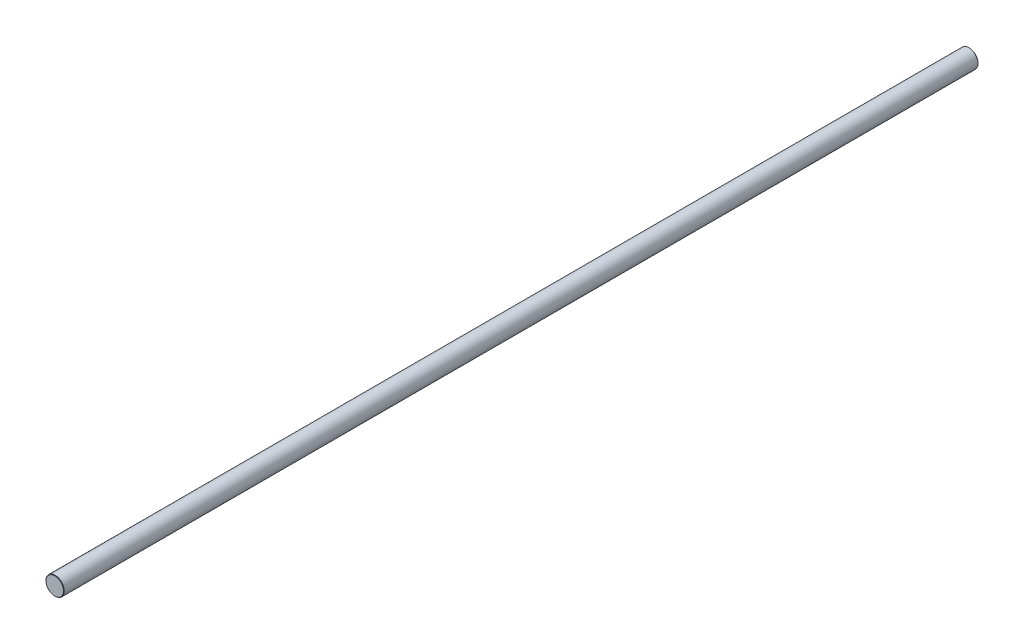
from build123d import *

# Parameters (mm, degrees)
SKETCH3_R                = 10
BOSS_EXTRUDE1_DEPTH      = 500
BOSS_EXTRUDE1_DEPTH_BACK = 500
CHAMFER1_SIZE            = 0.4


with BuildPart() as part:
    # Sketch3 → Boss-Extrude1 (new body, two sides)
    with BuildSketch(Plane.XY) as boss_extrude1_sk:
        Circle(SKETCH3_R)
    extrude(amount=BOSS_EXTRUDE1_DEPTH)
    extrude(boss_extrude1_sk.sketch, amount=-BOSS_EXTRUDE1_DEPTH_BACK)

    # Chamfer1
    chamfer1_edges = [part.edges().sort_by_distance(p)[0] for p in [
        (-10, 0, -500),
        (-10, 0, 500),
    ]]
    chamfer(chamfer1_edges, length=CHAMFER1_SIZE)


solid = part.part
